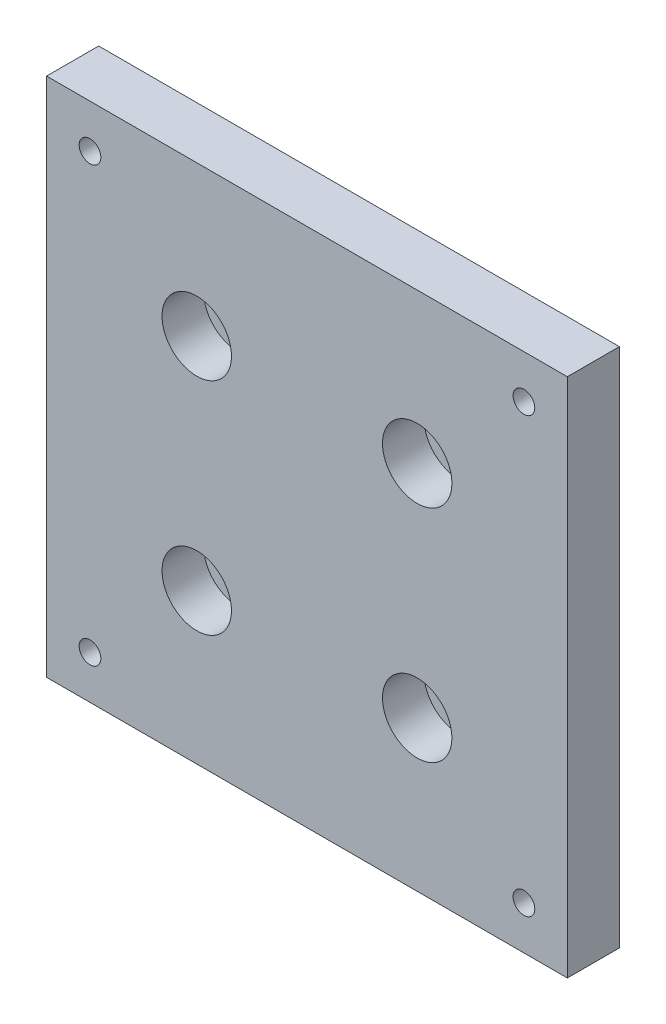
from build123d import *

# Parameters (mm, degrees)
SKETCH_1_W                = 60
SKETCH_1_H                = 60
EXTRUDE_1_DEPTH           = 6
HOLE_WIZARD_M3_1_D        = 2.5
HOLE_WIZARD_1_D           = 4
HOLE_WIZARD_1_CBORE_D     = 8
HOLE_WIZARD_1_CBORE_DEPTH = 4.8


with BuildPart() as part:
    # 草图1 → 凸台-拉伸1 (new body)
    with BuildSketch(Plane.XY):
        Rectangle(SKETCH_1_W, SKETCH_1_H)
    extrude(amount=EXTRUDE_1_DEPTH)

    # M3 螺纹孔1 (through all)
    with Locations(Plane(origin=(-25, 25, 6), x_dir=(1, 0, 0), z_dir=(0, 0, 1))):
        with Locations((0, 0), (50, 0), (50, -50), (0, -50)):
            Hole(HOLE_WIZARD_M3_1_D / 2)

    # 孔1 (through all)
    with Locations(Plane(origin=(-12.7, 12.7, 6), x_dir=(1, 0, 0), z_dir=(0, 0, 1))):
        with Locations((0, 0), (25.4, 0), (25.4, -25.4), (0, -25.4)):
            CounterBoreHole(HOLE_WIZARD_1_D / 2, HOLE_WIZARD_1_CBORE_D / 2, HOLE_WIZARD_1_CBORE_DEPTH)


solid = part.part
